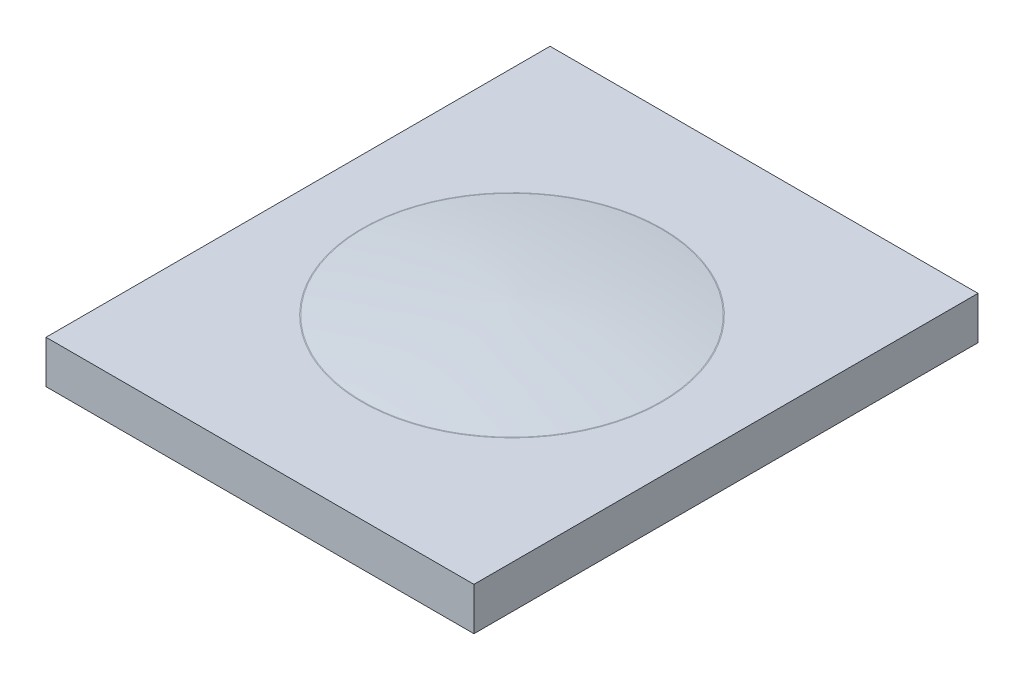
from build123d import *

# Parameters (mm, degrees)
SKETCH_1_W      = 90
SKETCH_1_H      = 106
EXTRUDE_1_DEPTH = 9
FILLET_1_R      = 1.1


with BuildPart() as part:
    # 草图1 → 凸台-拉伸1 (new body)
    with BuildSketch(Plane(origin=(0, 0, 0), x_dir=(1, 0, 0), z_dir=(0, 1, 0))):
        Rectangle(SKETCH_1_W, SKETCH_1_H)
    extrude(amount=EXTRUDE_1_DEPTH)

    # 草图2 → 旋转2 (revolve)
    with BuildSketch(Plane.XY):
        with BuildLine():
            Line((0, 9), (31.5, 9))
            ThreePointArc((31.5, 9), (15.79754743, 11), (0, 12.002253416))
            Line((0, 12.002253416), (0, 9))
        make_face()
    revolve(axis=Axis((0, 0, 0), (0, 1, 0)))

    # 圆角1
    fillet_1_edges = [part.edges().sort_by_distance(p)[0] for p in [
        (-31.5, 9, 0),
    ]]
    fillet(fillet_1_edges, radius=FILLET_1_R)


solid = part.part
